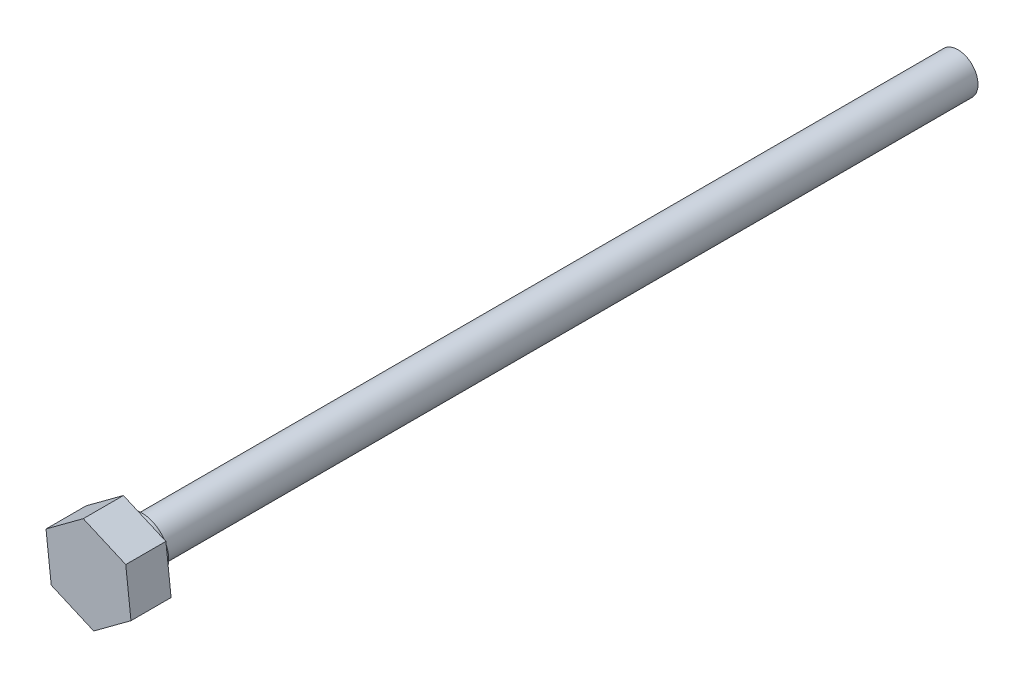
from build123d import *

# Parameters (mm, degrees)
BOSS_EXTRUDE1_DEPTH = 3
SKETCH2_R           = 2
BOSS_EXTRUDE2_DEPTH = 1
SKETCH4_R           = 1.5
BOSS_EXTRUDE3_DEPTH = 61


with BuildPart() as part:
    # Sketch1 → Boss-Extrude1 (new body)
    with BuildSketch(Plane.XY):
        Polygon((-3.176229493, 1.382594015), (-2.785476286, -2.059398422), (0.390753207, -3.441992436), (3.176229493, -1.382594015), (2.785476286, 2.059398422), (-0.390753207, 3.441992436), align=None)
    extrude(amount=BOSS_EXTRUDE1_DEPTH)

    # Sketch2 → Boss-Extrude2 (add)
    with BuildSketch(Plane.XY):
        Circle(SKETCH2_R)
    extrude(amount=-BOSS_EXTRUDE2_DEPTH)

    # Sketch4 → Boss-Extrude3 (add)
    with BuildSketch(Plane(origin=(0, 0, -1), x_dir=(-1, 0, 0), z_dir=(0, 0, -1))):
        Circle(SKETCH4_R)
    extrude(amount=BOSS_EXTRUDE3_DEPTH)


solid = part.part
